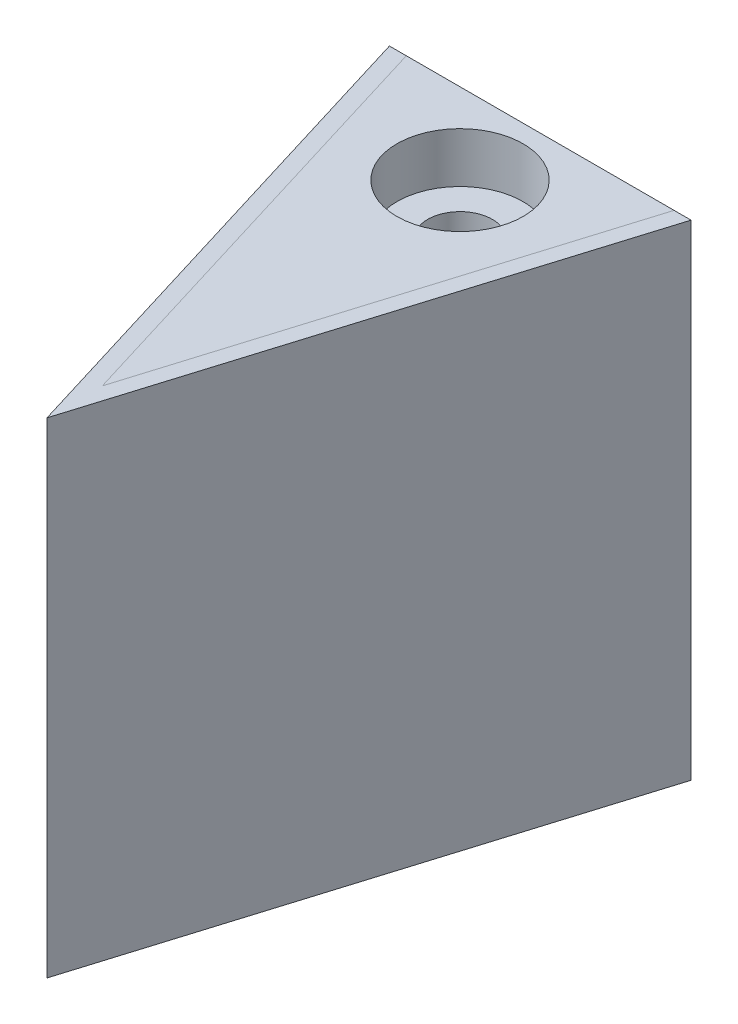
from build123d import *

# Parameters (mm, degrees)
BOSS_EXTRUDE1_DEPTH      = 12.5
BOSS_EXTRUDE1_DEPTH_BACK = 2.5
CUT_EXTRUDE1_DEPTH       = 5
SKETCH5_R                = 1
CUT_EXTRUDE2_DEPTH       = 22.965235397
CUT_EXTRUDE2_DEPTH_BACK  = 22.965235397
SKETCH6_R                = 1.95
CUT_EXTRUDE3_DEPTH       = 1.55
SPLIT3_SURFACE_1_BACK    = 24.335
SPLIT3_SURFACE_1_DEPTH   = 48.67
SPLIT3_SURFACE_2_BACK    = 24.335
SPLIT3_SURFACE_2_DEPTH   = 48.67


with BuildPart() as part:
    # Sketch1 → Boss-Extrude1 (new, two sides)
    with BuildSketch(Plane(origin=(0, 0, 0), x_dir=(1, 0, 0), z_dir=(0, 1, 0))) as boss_extrude1_sk:
        Polygon((4.642363604, -4.565370009), (-4.68242218, -4.565370009), (-1.013654003, -16.565370009), (-0.020029288, -19.815370009), (0.973595427, -16.565370009), align=None)
    extrude(amount=BOSS_EXTRUDE1_DEPTH)
    extrude(boss_extrude1_sk.sketch, amount=-BOSS_EXTRUDE1_DEPTH_BACK)

    # Sketch2 → Cut-Extrude1 (cut)
    with BuildSketch(Plane(origin=(0, 0, 4.565370009), x_dir=(-1, 0, 0), z_dir=(0, 0, -1))):
        with BuildLine():
            Line((-2.878246061, 5.95), (2.918304637, 5.95))
            ThreePointArc((2.918304637, 5.95), (0.020029288, 8.05), (-2.878246061, 5.95))
        make_face()
        with BuildLine():
            Line((-2.878246061, 4.05), (2.918304637, 4.05))
            ThreePointArc((2.918304637, 4.05), (0.020029288, 1.95), (-2.878246061, 4.05))
        make_face()
    extrude(amount=-CUT_EXTRUDE1_DEPTH, mode=Mode.SUBTRACT)

    # Sketch5 → Cut-Extrude2 (cut, two sides)
    with BuildSketch(Plane(origin=(0, 5.74, 0), x_dir=(1, 0, 0), z_dir=(0, 1, 0))) as cut_extrude2_sk:
        with Locations(Location((0, -7.065370009, 0), (0, 0, 270))):
            Circle(SKETCH5_R)
    extrude(amount=CUT_EXTRUDE2_DEPTH, mode=Mode.SUBTRACT)
    extrude(cut_extrude2_sk.sketch, amount=-CUT_EXTRUDE2_DEPTH_BACK, mode=Mode.SUBTRACT)

    # Sketch6 → Cut-Extrude3 (cut)
    with BuildSketch(Plane(origin=(0, 12.5, 0), x_dir=(1, 0, 0), z_dir=(0, 1, 0))):
        with Locations(Location((0, -7.065370009, 0), (0, 0, 270))):
            Circle(SKETCH6_R)
    extrude(amount=-CUT_EXTRUDE3_DEPTH, mode=Mode.SUBTRACT)


with BuildPart() as body_2:
    # Split3: the piece behind the surface
    add(part.part)
    # Split3 surface: a surface, the sketch's curves swept straight by 48.67 mm
    with BuildLine(Plane(origin=(0, 12.5, 0), x_dir=(1, 0, 0), z_dir=(0, 1, 0)).offset(-SPLIT3_SURFACE_1_BACK), mode=Mode.PRIVATE) as split3_surface_1_path:
        Line((-4.68242218, -4.565370009), (-0.020029288, -19.815370009))
        Line((-0.020029288, -19.815370009), (4.642363604, -4.565370009))
        Line((4.642363604, -4.565370009), (4.119517726, -4.565370009))
        Line((4.119517726, -4.565370009), (-0.020029288, -18.105218199))
        Line((-0.020029288, -18.105218199), (-4.159576302, -4.565370009))
        Line((-4.159576302, -4.565370009), (-4.68242218, -4.565370009))
    split3_surface_1 = Shell.extrude(split3_surface_1_path.wire(), (0 * SPLIT3_SURFACE_1_DEPTH, 1 * SPLIT3_SURFACE_1_DEPTH, 0 * SPLIT3_SURFACE_1_DEPTH))
    split(bisect_by=split3_surface_1, keep=Keep.BOTTOM)


with BuildPart() as part_1:
    add(part.part)

    # Split3: split by a surface, the side it looks to stays
    # Split3 surface: a surface, the sketch's curves swept straight by 48.67 mm
    with BuildLine(Plane(origin=(0, 12.5, 0), x_dir=(1, 0, 0), z_dir=(0, 1, 0)).offset(-SPLIT3_SURFACE_2_BACK), mode=Mode.PRIVATE) as split3_surface_2_path:
        Line((-4.68242218, -4.565370009), (-0.020029288, -19.815370009))
        Line((-0.020029288, -19.815370009), (4.642363604, -4.565370009))
        Line((4.642363604, -4.565370009), (4.119517726, -4.565370009))
        Line((4.119517726, -4.565370009), (-0.020029288, -18.105218199))
        Line((-0.020029288, -18.105218199), (-4.159576302, -4.565370009))
        Line((-4.159576302, -4.565370009), (-4.68242218, -4.565370009))
    split3_surface_2 = Shell.extrude(split3_surface_2_path.wire(), (0 * SPLIT3_SURFACE_2_DEPTH, 1 * SPLIT3_SURFACE_2_DEPTH, 0 * SPLIT3_SURFACE_2_DEPTH))
    split(bisect_by=split3_surface_2, keep=Keep.TOP)


solid = Compound([body_2.part, part_1.part])
